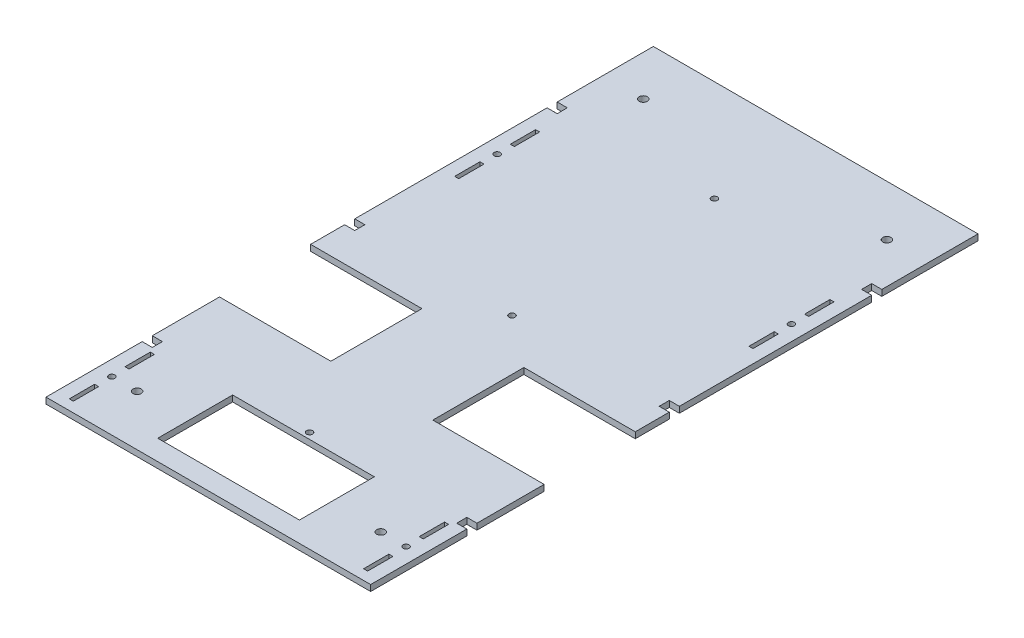
from build123d import *

# Parameters (mm, degrees)
SCHIZZO1_W                   = 160.36
SCHIZZO1_H                   = 300
ESTRUSIONE_ESTRUSIONE1_DEPTH = 3
SCHIZZO3_R                   = 1.5
SCHIZZO3_W                   = 5
SCHIZZO3_H                   = 5
SCHIZZO3_W_2                 = 55
SCHIZZO3_H_2                 = 45
TAGLIO_ESTRUSIONE1_DEPTH     = 4
SCHIZZO4_R                   = 2
TAGLIO_ESTRUSIONE2_DEPTH     = 4
SCHIZZO5_R                   = 1.5
SCHIZZO5_W                   = 2
SCHIZZO5_H                   = 12.5
TAGLIO_ESTRUSIONE3_DEPTH     = 4
SCHIZZO6_W                   = 70
SCHIZZO6_H                   = 37
TAGLIO_ESTRUSIONE4_DEPTH     = 4


with BuildPart() as part:
    # Schizzo1 → Estrusione-Estrusione1 (new body)
    with BuildSketch(Plane(origin=(0, 0, 0), x_dir=(1, 0, 0), z_dir=(0, 1, 0))):
        Rectangle(SCHIZZO1_W, SCHIZZO1_H)
    extrude(amount=ESTRUSIONE_ESTRUSIONE1_DEPTH)

    # Schizzo3 → Taglio-Estrusione1 (cut, through all)
    with BuildSketch(Plane(origin=(0, 0, 0), x_dir=(1, 0, 0), z_dir=(0, 1, 0))):
        Circle(SCHIZZO3_R)
        with Locations((0, -100)):
            Circle(SCHIZZO3_R)
        with Locations((0, 100)):
            Circle(SCHIZZO3_R)
        with Locations((-5.042705223, -204.043249359)):
            Circle(SCHIZZO3_R)
        with Locations((-77.68, -100)):
            Rectangle(SCHIZZO3_W, SCHIZZO3_H)
        with Locations((-77.68, 0)):
            Rectangle(SCHIZZO3_W, SCHIZZO3_H)
        with Locations((-77.68, 100)):
            Rectangle(SCHIZZO3_W, SCHIZZO3_H)
        with Locations((77.68, -100)):
            Rectangle(SCHIZZO3_W, SCHIZZO3_H)
        with Locations((77.68, 0)):
            Rectangle(SCHIZZO3_W, SCHIZZO3_H)
        with Locations((77.68, 100)):
            Rectangle(SCHIZZO3_W, SCHIZZO3_H)
        with Locations((-52.68, -41.8)):
            Rectangle(SCHIZZO3_W_2, SCHIZZO3_H_2)
        with Locations((52.68, -41.8)):
            Rectangle(SCHIZZO3_W_2, SCHIZZO3_H_2)
    extrude(amount=TAGLIO_ESTRUSIONE1_DEPTH, mode=Mode.SUBTRACT)

    # Schizzo4 → Taglio-Estrusione2 (cut, through all)
    with BuildSketch(Plane(origin=(0, 0, 0), x_dir=(1, 0, 0), z_dir=(0, 1, 0))):
        with Locations((-60.18, -125)):
            Circle(SCHIZZO4_R)
        with Locations((60.18, -125)):
            Circle(SCHIZZO4_R)
        with Locations((-60.18, 125)):
            Circle(SCHIZZO4_R)
        with Locations((60.18, 125)):
            Circle(SCHIZZO4_R)
    extrude(amount=TAGLIO_ESTRUSIONE2_DEPTH, mode=Mode.SUBTRACT)

    # Schizzo5 → Taglio-Estrusione3 (cut, through all)
    with BuildSketch(Plane(origin=(0, 0, 0), x_dir=(1, 0, 0), z_dir=(0, 1, 0))):
        with Locations((72.68, 65.35)):
            Circle(SCHIZZO5_R)
        with Locations((-72.68, 65.35)):
            Circle(SCHIZZO5_R)
        with Locations((72.68, -125)):
            Circle(SCHIZZO5_R)
        with Locations((-72.68, -125)):
            Circle(SCHIZZO5_R)
        with Locations((72.68, 79.1)):
            Rectangle(SCHIZZO5_W, SCHIZZO5_H)
        with Locations((72.68, 51.6)):
            Rectangle(SCHIZZO5_W, SCHIZZO5_H)
        with Locations((-72.68, 51.6)):
            Rectangle(SCHIZZO5_W, SCHIZZO5_H)
        with Locations((-72.68, 79.1)):
            Rectangle(SCHIZZO5_W, SCHIZZO5_H)
        with Locations((72.68, -111.25)):
            Rectangle(SCHIZZO5_W, SCHIZZO5_H)
        with Locations((72.68, -138.75)):
            Rectangle(SCHIZZO5_W, SCHIZZO5_H)
        with Locations((-72.68, -111.25)):
            Rectangle(SCHIZZO5_W, SCHIZZO5_H)
        with Locations((-72.68, -138.75)):
            Rectangle(SCHIZZO5_W, SCHIZZO5_H)
    extrude(amount=TAGLIO_ESTRUSIONE3_DEPTH, mode=Mode.SUBTRACT)

    # Schizzo6 → Taglio-Estrusione4 (cut, through all)
    with BuildSketch(Plane(origin=(0, 0, 0), x_dir=(1, 0, 0), z_dir=(0, 1, 0))):
        with Locations((0, -121.5)):
            Rectangle(SCHIZZO6_W, SCHIZZO6_H)
    extrude(amount=TAGLIO_ESTRUSIONE4_DEPTH, mode=Mode.SUBTRACT)


solid = part.part
